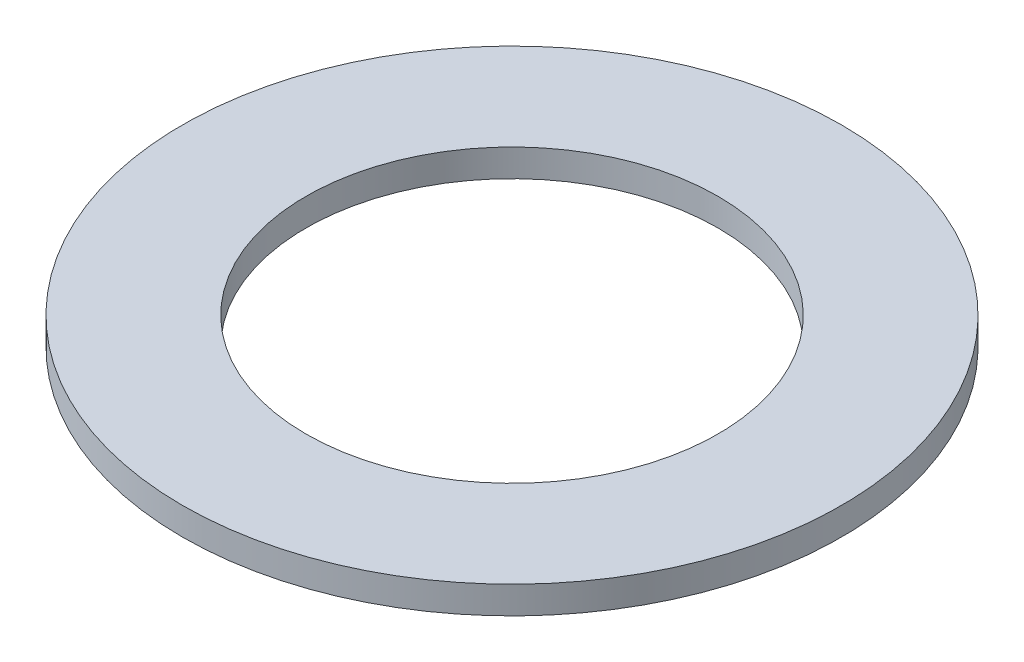
from build123d import *

# Parameters (mm, degrees)
SKETCH1_R         = 12
SKETCH1_R_2       = 7.5
PDMS_GASKET_DEPTH = 1


with BuildPart() as part:
    # Sketch1 → PDMS Gasket (new body)
    with BuildSketch(Plane(origin=(0, 0, 0), x_dir=(1, 0, 0), z_dir=(0, 1, 0))):
        Circle(SKETCH1_R)
        Circle(SKETCH1_R_2, mode=Mode.SUBTRACT)
    extrude(amount=PDMS_GASKET_DEPTH)


solid = part.part
